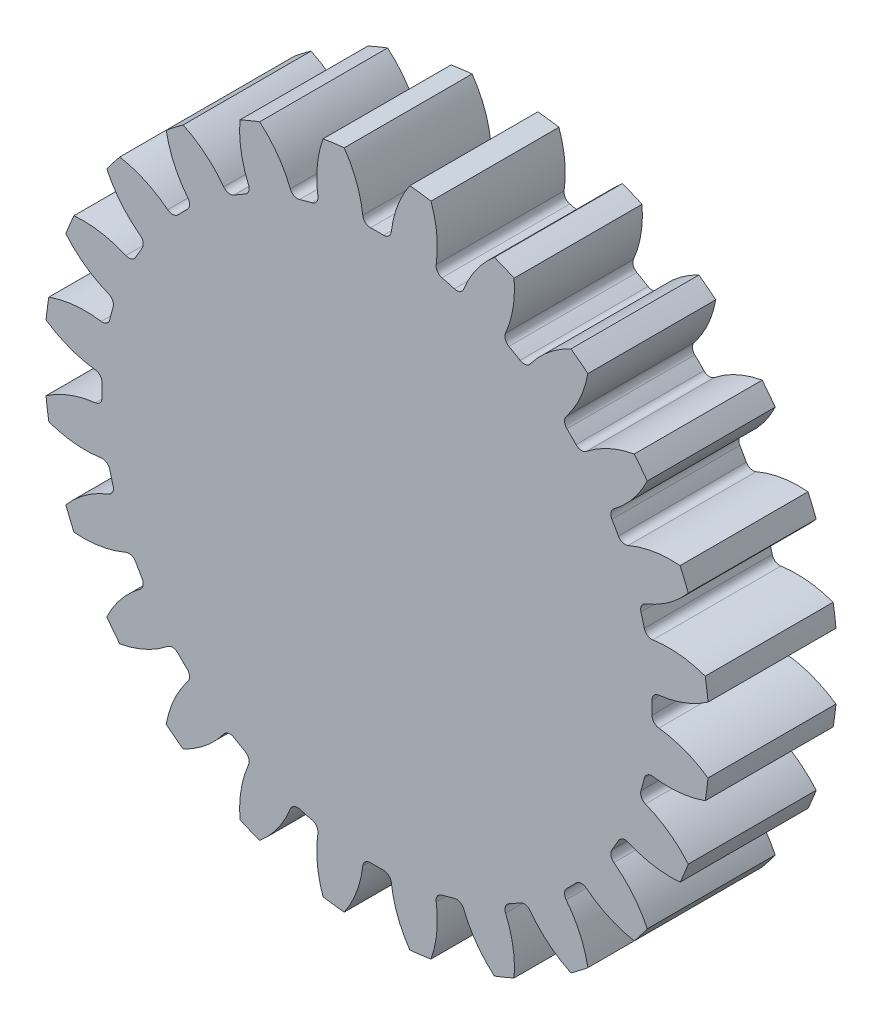
from build123d import *

# Parameters (mm, degrees)
SKETCH2_R                = 26
BOSS_EXTRUDE1_DEPTH      = 5
CUT_EXTRUDE1_DEPTH       = 6
FILLET1_R                = 0.6
CIRPATTERN1_COUNT        = 24
FILLET1_OF_CIRPATTERN1_R = 0.6


with BuildPart() as part:
    # Sketch2 → Boss-Extrude1 (new body, symmetric)
    with BuildSketch(Plane.XY):
        Circle(SKETCH2_R)
    extrude(amount=BOSS_EXTRUDE1_DEPTH, both=True)

    # Sketch3 → Cut-Extrude1 (cut, symmetric)
    with BuildSketch(Plane.XY):
        with BuildLine():
            ThreePointArc((-1.069432211, 21.473386197), (-1.719697623, 24.33159319), (-3.305383752, 26.796910983))
            ThreePointArc((-3.305383752, 26.796910983), (0, 27), (3.305383752, 26.796910983))
            ThreePointArc((3.305383752, 26.796910983), (1.719697623, 24.33159319), (1.069432211, 21.473386197))
            ThreePointArc((1.069432211, 21.473386197), (0, 21.5), (-1.069432211, 21.473386197))
        make_face()
    cut_extrude1 = extrude(amount=CUT_EXTRUDE1_DEPTH, both=True, mode=Mode.SUBTRACT)

    # Fillet1
    fillet1_edges = [part.edges().sort_by_distance(p)[0] for p in [
        (-1.069432211, 21.473386197, 0),
        (1.069432211, 21.473386197, 0),
    ]]
    fillet(fillet1_edges, radius=FILLET1_R)

    # CirPattern1: Cut-Extrude1 ×24 about axis
    cirpattern1_axis = Axis((0, 0, 0), (0, 0, 1))
    for i in range(1, CIRPATTERN1_COUNT):
        add(cut_extrude1.rotate(cirpattern1_axis, i * 360 / CIRPATTERN1_COUNT), mode=Mode.SUBTRACT)

    # Fillet1 of CirPattern1
    fillet1_of_cirpattern1_edges = [part.edges().sort_by_distance(p)[0] for p in [
        (-6.590713502, 20.464908882, 0),
        (-4.524729119, 21.018487729, 0),
        (-11.66284856, 18.061781846, 0),
        (-9.810537636, 19.131214057, 0),
        (-15.940179763, 14.427774227, 0),
        (-14.427774227, 15.940179763, 0),
        (-19.131214057, 9.810537636, 0),
        (-18.061781846, 11.66284856, 0),
        (-21.018487729, 4.524729119, 0),
        (-20.464908882, 6.590713502, 0),
        (-21.473386197, -1.069432211, 0),
        (-21.473386197, 1.069432211, 0),
        (-20.464908882, -6.590713502, 0),
        (-21.018487729, -4.524729119, 0),
        (-18.061781846, -11.66284856, 0),
        (-19.131214057, -9.810537636, 0),
        (-14.427774227, -15.940179763, 0),
        (-15.940179763, -14.427774227, 0),
        (-9.810537636, -19.131214057, 0),
        (-11.66284856, -18.061781846, 0),
        (-4.524729119, -21.018487729, 0),
        (-6.590713502, -20.464908882, 0),
        (1.069432211, -21.473386197, 0),
        (-1.069432211, -21.473386197, 0),
        (6.590713502, -20.464908882, 0),
        (4.524729119, -21.018487729, 0),
        (11.66284856, -18.061781846, 0),
        (9.810537636, -19.131214057, 0),
        (15.940179763, -14.427774227, 0),
        (14.427774227, -15.940179763, 0),
        (19.131214057, -9.810537636, 0),
        (18.061781846, -11.66284856, 0),
        (21.018487729, -4.524729119, 0),
        (20.464908882, -6.590713502, 0),
        (21.473386197, 1.069432211, 0),
        (21.473386197, -1.069432211, 0),
        (20.464908882, 6.590713502, 0),
        (21.018487729, 4.524729119, 0),
        (18.061781846, 11.66284856, 0),
        (19.131214057, 9.810537636, 0),
        (14.427774227, 15.940179763, 0),
        (15.940179763, 14.427774227, 0),
        (9.810537636, 19.131214057, 0),
        (11.66284856, 18.061781846, 0),
        (4.524729119, 21.018487729, 0),
        (6.590713502, 20.464908882, 0),
    ]]
    fillet(fillet1_of_cirpattern1_edges, radius=FILLET1_OF_CIRPATTERN1_R)


solid = part.part
